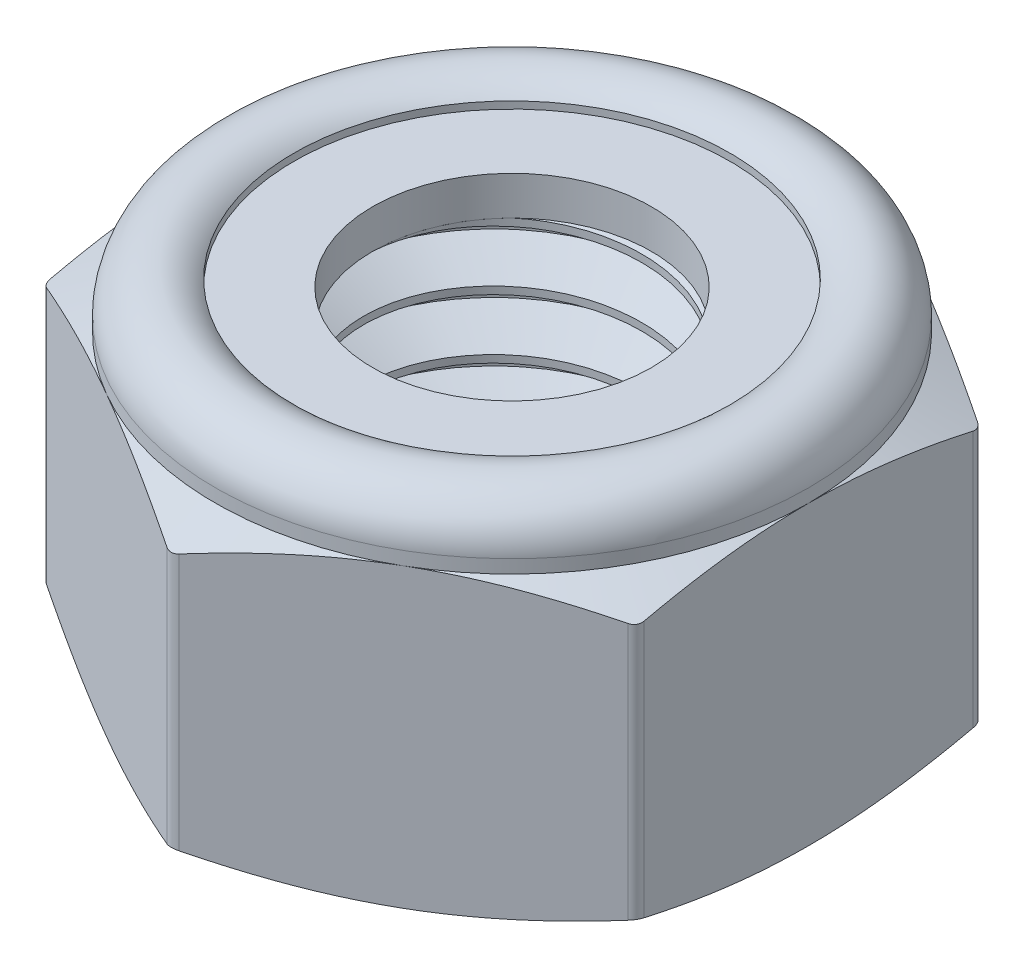
from build123d import *

# Parameters (mm, degrees)
SKETCH2_R                = 2.350480947
BOSS_EXTRUDE1_DEPTH      = 3
BOSS_EXTRUDE1_DEPTH_BACK = 3
FILLET1_R                = 0.2
SKETCH4_W                = 1.324759527
SKETCH4_H                = 0.652707199
SKETCH6_W                = 3
SKETCH6_H                = 5
CUT_SWEEP1_PITCH         = 1
CUT_SWEEP1_HEIGHT        = 6
CUT_SWEEP1_RADIUS        = 3
CUT_SWEEP1_START_ANGLE   = 90
SKETCH10_R               = 2.950480947
BOSS_EXTRUDE2_DEPTH      = 5


with BuildPart() as part:
    # Sketch2 → Boss-Extrude1 (new, two sides)
    with BuildSketch(Plane(origin=(0, 0, 0), x_dir=(1, 0, 0), z_dir=(0, 1, 0))) as boss_extrude1_sk:
        Polygon((0, 5.773502692), (-5, 2.886751346), (-5, -2.886751346), (0, -5.773502692), (5, -2.886751346), (5, 2.886751346), align=None)
        with Locations(Location((0, 0, 0), (0, 0, 270))):
            Circle(SKETCH2_R, mode=Mode.SUBTRACT)
    extrude(amount=BOSS_EXTRUDE1_DEPTH)
    extrude(boss_extrude1_sk.sketch, amount=-BOSS_EXTRUDE1_DEPTH_BACK)

    # Fillet1
    fillet1_edges = [part.edges().sort_by_distance(p)[0] for p in [
        (5, 0, -2.886751346),
        (5, 0, 2.886751346),
        (0, 0, 5.773502692),
        (-5, 0, 2.886751346),
        (-5, 0, -2.886751346),
        (0, 0, -5.773502692),
    ]]
    fillet(fillet1_edges, radius=FILLET1_R)

    # Sketch3 → Cut-Revolve2 (revolve, cut)
    with BuildSketch(Plane(origin=(0, 0, 0), x_dir=(0, 0, -1), z_dir=(1, 0, 0)), mode=Mode.PRIVATE) as cut_revolve2_sk:
        with BuildLine():
            Line((5.773502692, 2), (5.773502692, 4))
            Line((5.773502692, 4), (2.350480947, 4))
            Line((2.350480947, 4), (2.350480947, 2))
            Line((2.350480947, 2), (3.675240474, 2))
            Line((3.675240474, 2), (3.675240474, 2.772707199))
            ThreePointArc((3.675240474, 2.772707199), (4.520946192, 2.940928526), (5, 2.223973836))
            Line((5, 2.223973836), (5, 2))
            Line((5, 2), (5.773502692, 1.639309771))
            Line((5.773502692, 1.639309771), (5.773502692, 2))
        make_face()
        Polygon((5, -3), (5.773502692, -2.639309771), (5.773502692, -3), align=None)
        Polygon((2.350480947, -3), (2.350480947, -2.4), (2.950480947, -3), align=None)
    revolve(cut_revolve2_sk.sketch.rotate(Axis((0, -3, 0), (0, 1, 0)), 270), axis=Axis((0, -3, 0), (0, 1, 0)), mode=Mode.SUBTRACT)

    # Sketch10 → Boss-Extrude2 (add)
    with BuildSketch(Plane.XZ.offset(3)):
        Circle(SKETCH10_R)
    extrude(amount=-BOSS_EXTRUDE2_DEPTH)


with BuildPart() as body_2:
    # Sketch4 → Revolve1 (revolve)
    with BuildSketch(Plane(origin=(0, 0, 0), x_dir=(0, 0, -1), z_dir=(1, 0, 0)), mode=Mode.PRIVATE) as revolve1_sk:
        with Locations((-3.012860711, 2.326353599)):
            Rectangle(SKETCH4_W, SKETCH4_H)
    revolve(revolve1_sk.sketch.rotate(Axis((0, -3, 0), (0, 1, 0)), 90), axis=Axis((0, -3, 0), (0, 1, 0)))


with BuildPart() as body_3:
    # Sketch6 → Revolve2 (revolve)
    with BuildSketch(Plane.XY, mode=Mode.PRIVATE) as revolve2_sk:
        with Locations((1.5, -0.5)):
            Rectangle(SKETCH6_W, SKETCH6_H)
    revolve(revolve2_sk.sketch.rotate(Axis((0, -3, 0), (0, 1, 0)), 90), axis=Axis((0, -3, 0), (0, 1, 0)))

    # Cut-Sweep1: sweep along a helix
    with BuildLine() as cut_sweep1_path:
        add(Helix(CUT_SWEEP1_PITCH, CUT_SWEEP1_HEIGHT, CUT_SWEEP1_RADIUS, center=(0, -3, 0), direction=(0, 1, 0), mode=Mode.PRIVATE).rotate(Axis((0, -3, 0), (0, 1, 0)), CUT_SWEEP1_START_ANGLE))
    # Sketch8 → Cut-Sweep1 (sweep, cut)
    with BuildSketch(Plane.XY):
        Polygon((2.350480947, -3.375), (2.350480947, -3.5), (3.054126588, -3.90625), (3.108253175, -2.9375), align=None)
    sweep(path=cut_sweep1_path.line, is_frenet=True, mode=Mode.SUBTRACT)

    # Sketch9 → Revolve3 (revolve)
    with BuildSketch(Plane.XY, mode=Mode.PRIVATE) as revolve3_sk:
        Polygon((0, 0), (0, -3), (3, -3), (3.6, -3), (0, 0.6), align=None)
    revolve(revolve3_sk.sketch.rotate(Axis((0, 0, 0), (0, -1, 0)), 90.182506618), axis=Axis((0, 0, 0), (0, -1, 0)))


with BuildPart() as part_1:
    add(part.part)

    # Combine1: cut body 3
    add(body_3.part, mode=Mode.SUBTRACT)


solid = Compound([body_2.part, part_1.part])
